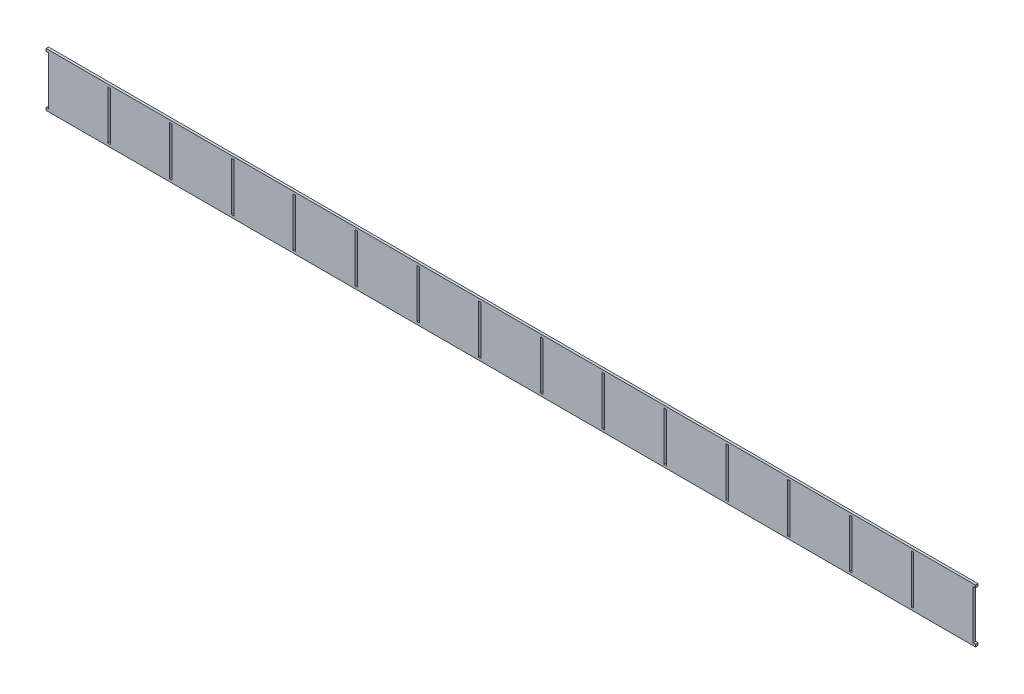
from build123d import *

# Parameters (mm, degrees)
BOSS_EXTRUDE1_DEPTH = 4
BOSS_EXTRUDE2_DEPTH = 4


with BuildPart() as part:
    # Sketch2 → Boss-Extrude1 (new body)
    with BuildSketch(Plane.XY):
        Polygon((725.508397322, 45.210025961), (-778.491602678, 45.210025961), (-778.491602678, 41.210025961), (-774.491602678, 41.210025961), (-774.491602678, 1.805025961), (-750.491602678, 1.805025961), (-756.491602678, 9.805025961), (-732.491602678, 9.805025961), (-738.491602678, 1.805025961), (-714.491602678, 1.805025961), (-720.491602678, 9.805025961), (-696.491602678, 9.805025961), (-702.491602678, 1.805025961), (-678.491602678, 1.805025961), (-678.491602678, 41.210025961), (-674.491602678, 41.210025961), (-674.491602678, 1.805025961), (-650.491602678, 1.805025961), (-656.491602678, 9.805025961), (-632.491602678, 9.805025961), (-638.491602678, 1.805025961), (-614.491602678, 1.805025961), (-620.491602678, 9.805025961), (-596.491602678, 9.805025961), (-602.491602678, 1.805025961), (-578.491602678, 1.805025961), (-578.491602678, 41.210025961), (-574.491602678, 41.210025961), (-574.491602678, 1.805025961), (-550.491602678, 1.805025961), (-556.491602678, 9.805025961), (-532.491602678, 9.805025961), (-538.491602678, 1.805025961), (-514.491602678, 1.805025961), (-520.491602678, 9.805025961), (-496.491602678, 9.805025961), (-502.491602678, 1.805025961), (-478.491602678, 1.805025961), (-478.491602678, 41.210025961), (-474.491602678, 41.210025961), (-474.491602678, 1.805025961), (-450.491602678, 1.805025961), (-456.491602678, 9.805025961), (-432.491602678, 9.805025961), (-438.491602678, 1.805025961), (-414.491602678, 1.805025961), (-420.491602678, 9.805025961), (-396.491602678, 9.805025961), (-402.491602678, 1.805025961), (-378.491602678, 1.805025961), (-378.491602678, 41.210025961), (-374.491602678, 41.210025961), (-374.491602678, 1.805025961), (-350.491602678, 1.805025961), (-356.491602678, 9.805025961), (-332.491602678, 9.805025961), (-338.491602678, 1.805025961), (-314.491602678, 1.805025961), (-320.491602678, 9.805025961), (-296.491602678, 9.805025961), (-302.491602678, 1.805025961), (-278.491602678, 1.805025961), (-278.491602678, 41.210025961), (-274.491602678, 41.210025961), (-274.491602678, 1.805025961), (-250.491602678, 1.805025961), (-256.491602678, 9.805025961), (-232.491602678, 9.805025961), (-238.491602678, 1.805025961), (-214.491602678, 1.805025961), (-220.491602678, 9.805025961), (-196.491602678, 9.805025961), (-202.491602678, 1.805025961), (-178.491602678, 1.805025961), (-178.491602678, 41.210025961), (-174.491602678, 41.210025961), (-174.491602678, 1.805025961), (-150.491602678, 1.805025961), (-156.491602678, 9.805025961), (-132.491602678, 9.805025961), (-138.491602678, 1.805025961), (-114.491602678, 1.805025961), (-120.491602678, 9.805025961), (-96.491602678, 9.805025961), (-102.491602678, 1.805025961), (-78.491602678, 1.805025961), (-78.491602678, 41.210025961), (-74.491602678, 41.210025961), (-74.491602678, 1.805025961), (-50.491602678, 1.805025961), (-56.491602678, 9.805025961), (-32.491602678, 9.805025961), (-38.491602678, 1.805025961), (-14.491602678, 1.805025961), (-20.491602678, 9.805025961), (3.508397322, 9.805025961), (-2.491602678, 1.805025961), (21.508397322, 1.805025961), (21.508397322, 41.210025961), (25.508397322, 41.210025961), (25.508397322, 1.805025961), (49.508397322, 1.805025961), (43.508397322, 9.805025961), (67.508397322, 9.805025961), (61.508397322, 1.805025961), (85.508397322, 1.805025961), (79.508397322, 9.805025961), (103.508397322, 9.805025961), (97.508397322, 1.805025961), (121.508397322, 1.805025961), (121.508397322, 41.210025961), (125.508397322, 41.210025961), (125.508397322, 1.805025961), (149.508397322, 1.805025961), (143.508397322, 9.805025961), (167.508397322, 9.805025961), (161.508397322, 1.805025961), (185.508397322, 1.805025961), (179.508397322, 9.805025961), (203.508397322, 9.805025961), (197.508397322, 1.805025961), (221.508397322, 1.805025961), (221.508397322, 41.210025961), (225.508397322, 41.210025961), (225.508397322, 1.805025961), (249.508397322, 1.805025961), (243.508397322, 9.805025961), (267.508397322, 9.805025961), (261.508397322, 1.805025961), (285.508397322, 1.805025961), (279.508397322, 9.805025961), (303.508397322, 9.805025961), (297.508397322, 1.805025961), (321.508397322, 1.805025961), (321.508397322, 41.210025961), (325.508397322, 41.210025961), (325.508397322, 1.805025961), (349.508397322, 1.805025961), (343.508397322, 9.805025961), (367.508397322, 9.805025961), (361.508397322, 1.805025961), (385.508397322, 1.805025961), (379.508397322, 9.805025961), (403.508397322, 9.805025961), (397.508397322, 1.805025961), (421.508397322, 1.805025961), (421.508397322, 41.210025961), (425.508397322, 41.210025961), (425.508397322, 1.805025961), (449.508397322, 1.805025961), (443.508397322, 9.805025961), (467.508397322, 9.805025961), (461.508397322, 1.805025961), (485.508397322, 1.805025961), (479.508397322, 9.805025961), (503.508397322, 9.805025961), (497.508397322, 1.805025961), (521.508397322, 1.805025961), (521.508397322, 41.210025961), (525.508397322, 41.210025961), (525.508397322, 1.805025961), (549.508397322, 1.805025961), (543.508397322, 9.805025961), (567.508397322, 9.805025961), (561.508397322, 1.805025961), (585.508397322, 1.805025961), (579.508397322, 9.805025961), (603.508397322, 9.805025961), (597.508397322, 1.805025961), (621.508397322, 1.805025961), (621.508397322, 41.210025961), (625.508397322, 41.210025961), (625.508397322, 1.805025961), (649.508397322, 1.805025961), (643.508397322, 9.805025961), (667.508397322, 9.805025961), (661.508397322, 1.805025961), (685.508397322, 1.805025961), (679.508397322, 9.805025961), (703.508397322, 9.805025961), (697.508397322, 1.805025961), (721.508397322, 1.805025961), (721.508397322, 41.210025961), (725.508397322, 41.210025961), align=None)
    extrude(amount=BOSS_EXTRUDE1_DEPTH)

    # Sketch3 → Boss-Extrude2 (add)
    with BuildSketch(Plane.XY.offset(4)):
        Polygon((-774.491602678, 1.805025961), (-774.491602678, -37.604974039), (-778.491602678, -37.604974039), (-778.491602678, -41.604974039), (725.508397322, -41.604974039), (725.508397322, -37.604974039), (721.508397322, -37.604974039), (721.508397322, 1.805025961), (697.508397322, 1.805025961), (703.508397322, 9.805025961), (679.508397322, 9.805025961), (685.508397322, 1.805025961), (661.508397322, 1.805025961), (667.508397322, 9.805025961), (643.508397322, 9.805025961), (649.508397322, 1.805025961), (625.508397322, 1.805025961), (625.508397322, -37.604974039), (621.508397322, -37.604974039), (621.508397322, 1.805025961), (597.508397322, 1.805025961), (603.508397322, 9.805025961), (579.508397322, 9.805025961), (585.508397322, 1.805025961), (561.508397322, 1.805025961), (567.508397322, 9.805025961), (543.508397322, 9.805025961), (549.508397322, 1.805025961), (525.508397322, 1.805025961), (525.508397322, -37.604974039), (521.508397322, -37.604974039), (521.508397322, 1.805025961), (497.508397322, 1.805025961), (503.508397322, 9.805025961), (479.508397322, 9.805025961), (485.508397322, 1.805025961), (461.508397322, 1.805025961), (467.508397322, 9.805025961), (443.508397322, 9.805025961), (449.508397322, 1.805025961), (425.508397322, 1.805025961), (425.508397322, -37.604974039), (421.508397322, -37.604974039), (421.508397322, 1.805025961), (397.508397322, 1.805025961), (403.508397322, 9.805025961), (379.508397322, 9.805025961), (385.508397322, 1.805025961), (361.508397322, 1.805025961), (367.508397322, 9.805025961), (343.508397322, 9.805025961), (349.508397322, 1.805025961), (325.508397322, 1.805025961), (325.508397322, -37.604974039), (321.508397322, -37.604974039), (321.508397322, 1.805025961), (297.508397322, 1.805025961), (303.508397322, 9.805025961), (279.508397322, 9.805025961), (285.508397322, 1.805025961), (261.508397322, 1.805025961), (267.508397322, 9.805025961), (243.508397322, 9.805025961), (249.508397322, 1.805025961), (225.508397322, 1.805025961), (225.508397322, -37.604974039), (221.508397322, -37.604974039), (221.508397322, 1.805025961), (197.508397322, 1.805025961), (203.508397322, 9.805025961), (179.508397322, 9.805025961), (185.508397322, 1.805025961), (161.508397322, 1.805025961), (167.508397322, 9.805025961), (143.508397322, 9.805025961), (149.508397322, 1.805025961), (125.508397322, 1.805025961), (125.508397322, -37.604974039), (121.508397322, -37.604974039), (121.508397322, 1.805025961), (97.508397322, 1.805025961), (103.508397322, 9.805025961), (79.508397322, 9.805025961), (85.508397322, 1.805025961), (61.508397322, 1.805025961), (67.508397322, 9.805025961), (43.508397322, 9.805025961), (49.508397322, 1.805025961), (25.508397322, 1.805025961), (25.508397322, -37.604974039), (21.508397322, -37.604974039), (21.508397322, 1.805025961), (-2.491602678, 1.805025961), (3.508397322, 9.805025961), (-20.491602678, 9.805025961), (-14.491602678, 1.805025961), (-38.491602678, 1.805025961), (-32.491602678, 9.805025961), (-56.491602678, 9.805025961), (-50.491602678, 1.805025961), (-74.491602678, 1.805025961), (-74.491602678, -37.604974039), (-78.491602678, -37.604974039), (-78.491602678, 1.805025961), (-102.491602678, 1.805025961), (-96.491602678, 9.805025961), (-120.491602678, 9.805025961), (-114.491602678, 1.805025961), (-138.491602678, 1.805025961), (-132.491602678, 9.805025961), (-156.491602678, 9.805025961), (-150.491602678, 1.805025961), (-174.491602678, 1.805025961), (-174.491602678, -37.604974039), (-178.491602678, -37.604974039), (-178.491602678, 1.805025961), (-202.491602678, 1.805025961), (-196.491602678, 9.805025961), (-220.491602678, 9.805025961), (-214.491602678, 1.805025961), (-238.491602678, 1.805025961), (-232.491602678, 9.805025961), (-256.491602678, 9.805025961), (-250.491602678, 1.805025961), (-274.491602678, 1.805025961), (-274.491602678, -37.604974039), (-278.491602678, -37.604974039), (-278.491602678, 1.805025961), (-302.491602678, 1.805025961), (-296.491602678, 9.805025961), (-320.491602678, 9.805025961), (-314.491602678, 1.805025961), (-338.491602678, 1.805025961), (-332.491602678, 9.805025961), (-356.491602678, 9.805025961), (-350.491602678, 1.805025961), (-374.491602678, 1.805025961), (-374.491602678, -37.604974039), (-378.491602678, -37.604974039), (-378.491602678, 1.805025961), (-402.491602678, 1.805025961), (-396.491602678, 9.805025961), (-420.491602678, 9.805025961), (-414.491602678, 1.805025961), (-438.491602678, 1.805025961), (-432.491602678, 9.805025961), (-456.491602678, 9.805025961), (-450.491602678, 1.805025961), (-474.491602678, 1.805025961), (-474.491602678, -37.604974039), (-478.491602678, -37.604974039), (-478.491602678, 1.805025961), (-502.491602678, 1.805025961), (-496.491602678, 9.805025961), (-520.491602678, 9.805025961), (-514.491602678, 1.805025961), (-538.491602678, 1.805025961), (-532.491602678, 9.805025961), (-556.491602678, 9.805025961), (-550.491602678, 1.805025961), (-574.491602678, 1.805025961), (-574.491602678, -37.604974039), (-578.491602678, -37.604974039), (-578.491602678, 1.805025961), (-602.491602678, 1.805025961), (-596.491602678, 9.805025961), (-620.491602678, 9.805025961), (-614.491602678, 1.805025961), (-638.491602678, 1.805025961), (-632.491602678, 9.805025961), (-656.491602678, 9.805025961), (-650.491602678, 1.805025961), (-674.491602678, 1.805025961), (-674.491602678, -37.604974039), (-678.491602678, -37.604974039), (-678.491602678, 1.805025961), (-702.491602678, 1.805025961), (-696.491602678, 9.805025961), (-720.491602678, 9.805025961), (-714.491602678, 1.805025961), (-738.491602678, 1.805025961), (-732.491602678, 9.805025961), (-756.491602678, 9.805025961), (-750.491602678, 1.805025961), align=None)
    extrude(amount=-BOSS_EXTRUDE2_DEPTH)


solid = part.part
